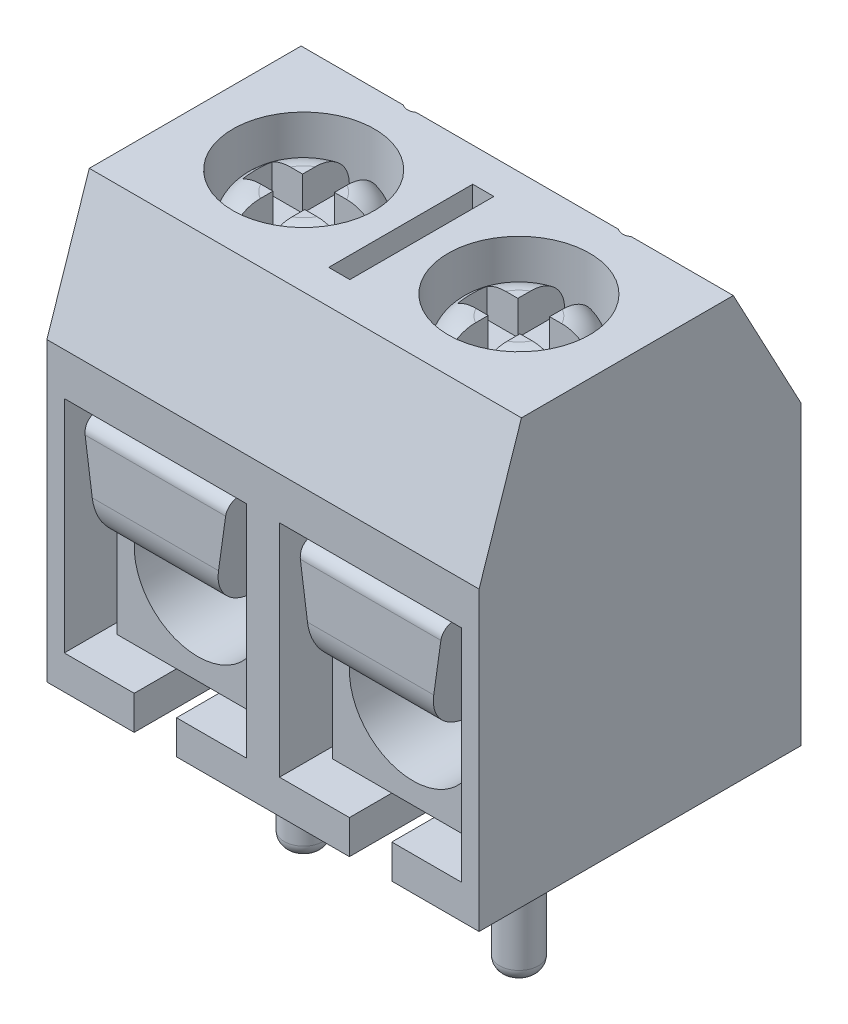
from build123d import *

# Parameters (mm, degrees)
BOSS_EXTRUDE1_DEPTH = 5.1
SKETCH3_R           = 1.67
CUT_EXTRUDE1_DEPTH  = 1.75
SKETCH4_R           = 0.25
SKETCH4_W           = 0.5
SKETCH4_H           = 3.4
CUT_EXTRUDE2_DEPTH  = 2
SKETCH5_W           = 4.3
SKETCH5_H           = 5.2
CUT_EXTRUDE3_DEPTH  = 6
CUT_EXTRUDE4_DEPTH  = 0.8
SKETCH9_R           = 1.5
BOSS_EXTRUDE5_DEPTH = 1.3
FILLET1_R           = 0.75
SKETCH10_W          = 0.75
SKETCH10_H          = 3.1
CUT_EXTRUDE5_DEPTH  = 0.8
SKETCH11_W          = 2.2
SKETCH11_H          = 0.7
CUT_EXTRUDE6_DEPTH  = 0.8
SKETCH7_W           = 9.38
SKETCH7_H           = 5.2
BOSS_EXTRUDE3_DEPTH = 0.5
SKETCH8_W           = 3.8
SKETCH8_H           = 5
SKETCH8_R           = 1.5
BOSS_EXTRUDE4_DEPTH = 4.5
FILLET2_R           = 0.2
BOSS_EXTRUDE6_DEPTH = 5.5
FILLET3_R           = 1
FILLET4_R           = 0.3
SKETCH13_R          = 0.46
BOSS_EXTRUDE7_DEPTH = 4.6
FILLET5_R           = 0.3


with BuildPart() as part:
    # Sketch1 → Boss-Extrude1 (new body, symmetric)
    with BuildSketch(Plane(origin=(0, 0, 0), x_dir=(0, 0, -1), z_dir=(1, 0, 0))):
        Polygon((-3.5, 0), (4.1, 0), (4.1, 7), (2.5, 10), (-2.5, 10), (-3.5, 7), align=None)
    extrude(amount=BOSS_EXTRUDE1_DEPTH, both=True)

    # Sketch3 → Cut-Extrude1 (cut)
    with BuildSketch(Plane(origin=(0, 10, 0), x_dir=(1, 0, 0), z_dir=(0, 1, 0))):
        with Locations((-2.54, 0)):
            Circle(SKETCH3_R)
        with Locations((2.54, 0)):
            Circle(SKETCH3_R)
    extrude(amount=-CUT_EXTRUDE1_DEPTH, mode=Mode.SUBTRACT)

    # Sketch4 → Cut-Extrude2 (cut)
    with BuildSketch(Plane(origin=(0, 10, 0), x_dir=(1, 0, 0), z_dir=(0, 1, 0))):
        with Locations((-2.54, 2.7)):
            Circle(SKETCH4_R)
        with Locations((2.54, 2.7)):
            Circle(SKETCH4_R)
        Rectangle(SKETCH4_W, SKETCH4_H)
    extrude(amount=-CUT_EXTRUDE2_DEPTH, mode=Mode.SUBTRACT)

    # Sketch5 → Cut-Extrude3 (cut)
    with BuildSketch(Plane.XY.offset(3.5)):
        with Locations((-2.54, 3.4)):
            Rectangle(SKETCH5_W, SKETCH5_H)
        with Locations((2.54, 3.4)):
            Rectangle(SKETCH5_W, SKETCH5_H)
    extrude(amount=-CUT_EXTRUDE3_DEPTH, mode=Mode.SUBTRACT)

    # Sketch6 → Cut-Extrude4 (cut)
    with BuildSketch(Plane.XZ):
        with BuildLine():
            Line((-3.04, 0), (-3.04, 3.5))
            ThreePointArc((-3.04, 3.5), (-2.54, 4), (-2.04, 3.5))
            Line((-2.04, 3.5), (-2.04, 0))
            ThreePointArc((-2.04, 0), (-2.54, -0.5), (-3.04, 0))
        make_face()
        with BuildLine():
            Line((2.04, 0), (2.04, 3.5))
            ThreePointArc((2.04, 3.5), (2.54, 4), (3.04, 3.5))
            Line((3.04, 3.5), (3.04, 0))
            ThreePointArc((3.04, 0), (2.54, -0.5), (2.04, 0))
        make_face()
    extrude(amount=-CUT_EXTRUDE4_DEPTH, mode=Mode.SUBTRACT)

    # Sketch9 → Boss-Extrude5 (add)
    with BuildSketch(Plane(origin=(0, 8.25, 0), x_dir=(1, 0, 0), z_dir=(0, 1, 0))):
        with Locations((2.54, 0)):
            Circle(SKETCH9_R)
        with Locations((-2.54, 0)):
            Circle(SKETCH9_R)
    extrude(amount=BOSS_EXTRUDE5_DEPTH)

    # Fillet1
    fillet1_edges = [part.edges().sort_by_distance(p)[0] for p in [
        (1.04, 9.55, 0),
        (-4.04, 9.55, 0),
    ]]
    fillet(fillet1_edges, radius=FILLET1_R)

    # Sketch10 → Cut-Extrude5 (cut)
    with BuildSketch(Plane(origin=(0, 9.55, 0), x_dir=(1, 0, 0), z_dir=(0, 1, 0))):
        with Locations((-2.54, 0)):
            Rectangle(SKETCH10_W, SKETCH10_H)
        with Locations((2.54, 0)):
            Rectangle(SKETCH10_W, SKETCH10_H)
    extrude(amount=-CUT_EXTRUDE5_DEPTH, mode=Mode.SUBTRACT)

    # Sketch11 → Cut-Extrude6 (cut)
    with BuildSketch(Plane(origin=(0, 9.55, 0), x_dir=(1, 0, 0), z_dir=(0, 1, 0))):
        with Locations((-2.54, 0)):
            Rectangle(SKETCH11_W, SKETCH11_H)
        with Locations((2.54, 0)):
            Rectangle(SKETCH11_W, SKETCH11_H)
    extrude(amount=-CUT_EXTRUDE6_DEPTH, mode=Mode.SUBTRACT)


with BuildPart() as body_2:
    # Sketch7 → Boss-Extrude3 (new body)
    with BuildSketch(Plane.XY.offset(-2.5)):
        with Locations((0, 3.4)):
            Rectangle(SKETCH7_W, SKETCH7_H)
    extrude(amount=BOSS_EXTRUDE3_DEPTH)

    # Sketch8 → Boss-Extrude4 (add)
    with BuildSketch(Plane.XY.offset(-2)):
        with Locations((-2.54, 3.3)):
            Rectangle(SKETCH8_W, SKETCH8_H)
        with Locations((-2.54, 2.8)):
            Circle(SKETCH8_R, mode=Mode.SUBTRACT)
        with Locations((2.54, 3.3)):
            Rectangle(SKETCH8_W, SKETCH8_H)
        with Locations((2.54, 2.8)):
            Circle(SKETCH8_R, mode=Mode.SUBTRACT)
    extrude(amount=BOSS_EXTRUDE4_DEPTH)

    # Fillet2
    fillet2_edges = [body_2.edges().sort_by_distance(p)[0] for p in [
        (-4.44, 5.8, 0.25),
        (-0.64, 5.8, 0.25),
        (0.64, 5.8, 0.25),
        (4.44, 5.8, 0.25),
    ]]
    fillet(fillet2_edges, radius=FILLET2_R)

    # Sketch12 → Boss-Extrude6 (add)
    with BuildSketch(Plane.XY.offset(3.5)):
        Polygon((-4.24, 5.8), (-0.84, 5.8), (-1.19, 3.3), (-3.89, 3.3), align=None)
        Polygon((0.84, 5.8), (4.24, 5.8), (3.89, 3.3), (1.19, 3.3), align=None)
    extrude(amount=-BOSS_EXTRUDE6_DEPTH)

    # Fillet3
    fillet3_edges = [body_2.edges().sort_by_distance(p)[0] for p in [
        (-2.54, 3.3, 3.5),
        (2.54, 3.3, 3.5),
    ]]
    fillet(fillet3_edges, radius=FILLET3_R)

    # Fillet4
    fillet4_edges = [body_2.edges().sort_by_distance(p)[0] for p in [
        (-2.54, 5.8, 3.5),
        (2.54, 5.8, 3.5),
    ]]
    fillet(fillet4_edges, radius=FILLET4_R)

    # Sketch13 → Boss-Extrude7 (add)
    with BuildSketch(Plane.XZ.offset(-0.8)):
        with Locations((2.54, 0)):
            Circle(SKETCH13_R)
        with Locations((-2.54, 0)):
            Circle(SKETCH13_R)
    extrude(amount=BOSS_EXTRUDE7_DEPTH)

    # Fillet5
    fillet5_edges = [body_2.edges().sort_by_distance(p)[0] for p in [
        (2.08, -3.8, 0),
        (-3, -3.8, 0),
    ]]
    fillet(fillet5_edges, radius=FILLET5_R)


solid = Compound([part.part, body_2.part])
